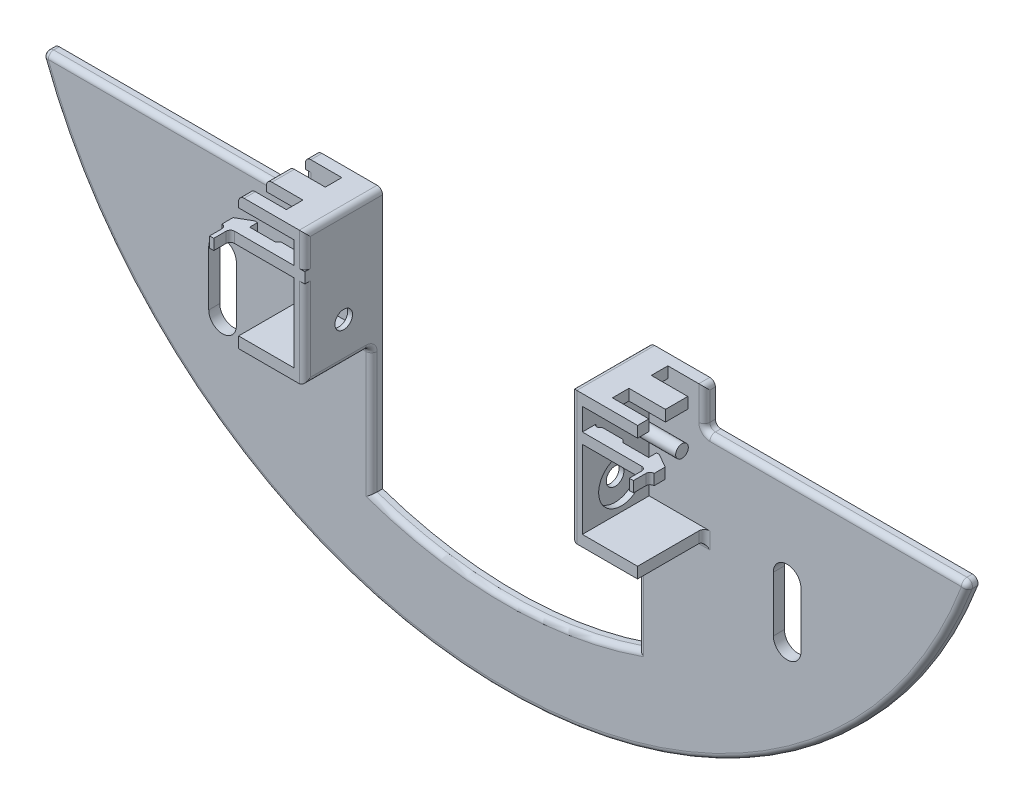
from build123d import *

# Parameters (mm, degrees)
BOSS_EXTRUDE1_DEPTH   = 2
BOSS_EXTRUDE2_DEPTH   = 12.1
SKETCH4_R             = 4.1
CUT_EXTRUDE1_DEPTH    = 1.12
SKETCH5_R             = 1.6
CUT_EXTRUDE2_DEPTH    = 49.18
SKETCH6_R             = 1.15
BOSS_EXTRUDE3_DEPTH   = 11
SKETCH8_W             = 15
SKETCH8_H             = 1.93
BOSS_EXTRUDE4_DEPTH   = 2
BOSS_EXTRUDE5_DEPTH   = 1.93
SKETCH10_W            = 6.61
SKETCH10_H            = 3
CUT_EXTRUDE3_DEPTH    = 3
FILLET1_R             = 1
F_5_0MM_DOWEL_HOLE1_D = 5
CUT_EXTRUDE4_DEPTH    = 3


with BuildPart() as part:
    # Sketch1 → Boss-Extrude1 (new body)
    with BuildSketch(Plane.XY):
        with BuildLine():
            Line((24.15, -30.4), (24.15, -23.330931672))
            Line((24.15, -23.330931672), (36.15, -23.330931672))
            Line((36.15, -23.330931672), (36.15, -30.4))
            Line((36.15, -30.4), (84.1789166, -30.4))
            ThreePointArc((84.1789166, -30.4), (0, -89.5), (-84.1789166, -30.4))
            Line((-84.1789166, -30.4), (-36.15, -30.4))
            Line((-36.15, -30.4), (-36.15, -23.330931672))
            Line((-36.15, -23.330931672), (-24.15, -23.330931672))
            Line((-24.15, -23.330931672), (-24.15, -30.4))
            Line((-24.15, -30.4), (-24.15, -70.477141684))
            ThreePointArc((-24.15, -70.477141684), (0, -74.5), (24.15, -70.477141684))
            Line((24.15, -70.477141684), (24.15, -30.4))
        make_face()
    extrude(amount=BOSS_EXTRUDE1_DEPTH)

    # Sketch3 → Boss-Extrude2 (add)
    with BuildSketch(Plane(origin=(0, 0, 2), x_dir=(-1, 0, 0), z_dir=(0, 0, -1))):
        Polygon((26.15, -45.430931672), (26.15, -25.330931672), (36.15, -25.330931672), (36.15, -23.330931672), (24.15, -23.330931672), (24.15, -47.430931672), (36.15, -47.430931672), (36.15, -45.430931672), align=None)
        Polygon((-36.15, -47.430931672), (-24.15, -47.430931672), (-24.15, -23.330931672), (-36.15, -23.330931672), (-36.15, -25.330931672), (-26.15, -25.330931672), (-26.15, -45.430931672), (-36.15, -45.430931672), align=None)
    extrude(amount=-BOSS_EXTRUDE2_DEPTH)

    # Sketch4 → Cut-Extrude1 (cut)
    with BuildSketch(Plane(origin=(26.15, 0, 0), x_dir=(0, 0, -1), z_dir=(1, 0, 0))):
        with Locations((-7.05, -40.380931672)):
            Circle(SKETCH4_R)
    cut_extrude1 = extrude(amount=-CUT_EXTRUDE1_DEPTH, mode=Mode.SUBTRACT)

    # Sketch5 → Cut-Extrude2 (cut)
    with BuildSketch(Plane(origin=(25.03, 0, 0), x_dir=(0, 0, -1), z_dir=(1, 0, 0))):
        with Locations((-7.05, -40.380931672)):
            Circle(SKETCH5_R)
    cut_extrude2 = extrude(amount=-CUT_EXTRUDE2_DEPTH, mode=Mode.SUBTRACT)

    # Sketch6 → Boss-Extrude3 (add)
    with BuildSketch(Plane(origin=(26.15, 0, 0), x_dir=(0, 0, -1), z_dir=(1, 0, 0))):
        with Locations((-7.05, -30.380931672)):
            Circle(SKETCH6_R)
    boss_extrude3 = extrude(amount=BOSS_EXTRUDE3_DEPTH)

    # Sketch8 → Boss-Extrude4 (add)
    with BuildSketch(Plane.XY.offset(14.1)):
        with Locations((31.65, -30.325931672)):
            Rectangle(SKETCH8_W, SKETCH8_H)
    boss_extrude4 = extrude(amount=-BOSS_EXTRUDE4_DEPTH)

    # Sketch9 → Boss-Extrude5 (add)
    with BuildSketch(Plane.XZ.offset(31.290931672)):
        Polygon((36.15, 12.1), (36.15, 10.656624327), (36.65, 10.656624327), (39.15, 12.1), align=None)
        with BuildLine():
            Line((26.15, 12.1), (31.51, 12.1))
            Line((31.51, 12.1), (31, 11.59))
            Line((31, 11.59), (27.258940086, 11.59))
            Line((27.258940086, 11.59), (26.995386696, 11.853553391))
            ThreePointArc((26.995386696, 11.853553391), (26.493019895, 11.977341145), (26.15, 11.59))
            Line((26.15, 11.59), (26.15, 12.1))
        make_face()
        with BuildLine():
            Line((38.400000259, 14.849999741), (38.400000259, 17.1))
            Line((38.400000259, 17.1), (37.650000259, 17.1))
            Line((37.650000259, 17.1), (37.650000259, 14.849999741))
            ThreePointArc((37.650000259, 14.849999741), (37.430330421, 14.319669838), (36.900000518, 14.1))
            Line((36.900000518, 14.1), (39.15, 14.1))
            ThreePointArc((39.15, 14.1), (38.619670097, 14.319669838), (38.400000259, 14.849999741))
        make_face()
    boss_extrude5 = extrude(amount=-BOSS_EXTRUDE5_DEPTH)

    # Sketch10 → Cut-Extrude3 (cut, through all)
    with BuildSketch(Plane.XZ.offset(25.330931672)):
        with Locations((32.845, 10.55)):
            Rectangle(SKETCH10_W, SKETCH10_H)
        with Locations((32.845, 3.5)):
            Rectangle(SKETCH10_W, SKETCH10_H)
    cut_extrude3 = extrude(amount=-CUT_EXTRUDE3_DEPTH, mode=Mode.SUBTRACT)

    # Fillet1
    fillet1_edges = [part.edges().sort_by_distance(p)[0] for p in [
        (36.15, -23.330931672, 1),
        (-60.1644583, -30.4, 2),
        (24.15, -23.330931672, 7.05),
        (36.15, -30.4, 1),
        (84.1789166, -30.4, 1),
        (-84.1789166, -30.4, 1),
        (-36.15, -30.4, 1),
        (-36.15, -23.330931672, 7.05),
        (-24.15, -23.330931672, 7.05),
        (0, -89.5, 2),
        (60.1644583, -30.4, 2),
        (36.15, -26.865465836, 2),
        (-36.15, -27.865465836, 2),
        (-24.15, -35.380931672, 14.1),
        (-24.15, -47.430931672, 8.05),
        (-30.15, -47.430931672, 2),
        (-36.15, -46.430931672, 2),
        (0, -74.5, 2),
        (-24.15, -58.954036678, 2),
        (24.15, -58.954036678, 2),
        (24.15, -35.380931672, 14.1),
        (24.15, -47.430931672, 8.05),
        (36.15, -46.430931672, 2),
        (30.15, -47.430931672, 2),
    ]]
    fillet(fillet1_edges, radius=FILLET1_R)

    # Ø5.0mm Dowel Hole1 (through all)
    with Locations(Plane(origin=(0, 0, -31.1), x_dir=(-1, 0, 0), z_dir=(0, 0, -1))):
        with Locations((-51.159778753, -51.159778753), (51.159778753, -51.159778753), (51.159778753, 51.159778753), (-51.159778753, 51.159778753)):
            Hole(F_5_0MM_DOWEL_HOLE1_D / 2)

    # Sketch13 → Cut-Extrude4 (cut, through all)
    with BuildSketch(Plane.XY.offset(2)):
        with BuildLine():
            Line((53.659778753, -46.159778753), (53.659778753, -56.159778753))
            ThreePointArc((53.659778753, -56.159778753), (51.159778753, -58.659778753), (48.659778753, -56.159778753))
            Line((48.659778753, -56.159778753), (48.659778753, -46.159778753))
            ThreePointArc((48.659778753, -46.159778753), (51.159778753, -43.659778753), (53.659778753, -46.159778753))
        make_face()
    cut_extrude4 = extrude(amount=-CUT_EXTRUDE4_DEPTH, mode=Mode.SUBTRACT)

    # Mirror1: Cut-Extrude1, Cut-Extrude2, Boss-Extrude3, Boss-Extrude4, Boss-Extrude5, Cut-Extrude3, Cut-Extrude4 across plane
    add(cut_extrude1.mirror(Plane(origin=(0, 0, 0), x_dir=(0, 0, 1), z_dir=(1, 0, 0))), mode=Mode.SUBTRACT)
    add(cut_extrude2.mirror(Plane(origin=(0, 0, 0), x_dir=(0, 0, 1), z_dir=(1, 0, 0))), mode=Mode.SUBTRACT)
    add(boss_extrude3.mirror(Plane(origin=(0, 0, 0), x_dir=(0, 0, 1), z_dir=(1, 0, 0))))
    add(boss_extrude4.mirror(Plane(origin=(0, 0, 0), x_dir=(0, 0, 1), z_dir=(1, 0, 0))))
    add(boss_extrude5.mirror(Plane(origin=(0, 0, 0), x_dir=(0, 0, 1), z_dir=(1, 0, 0))))
    add(cut_extrude3.mirror(Plane(origin=(0, 0, 0), x_dir=(0, 0, 1), z_dir=(1, 0, 0))), mode=Mode.SUBTRACT)
    add(cut_extrude4.mirror(Plane(origin=(0, 0, 0), x_dir=(0, 0, 1), z_dir=(1, 0, 0))), mode=Mode.SUBTRACT)


solid = part.part
